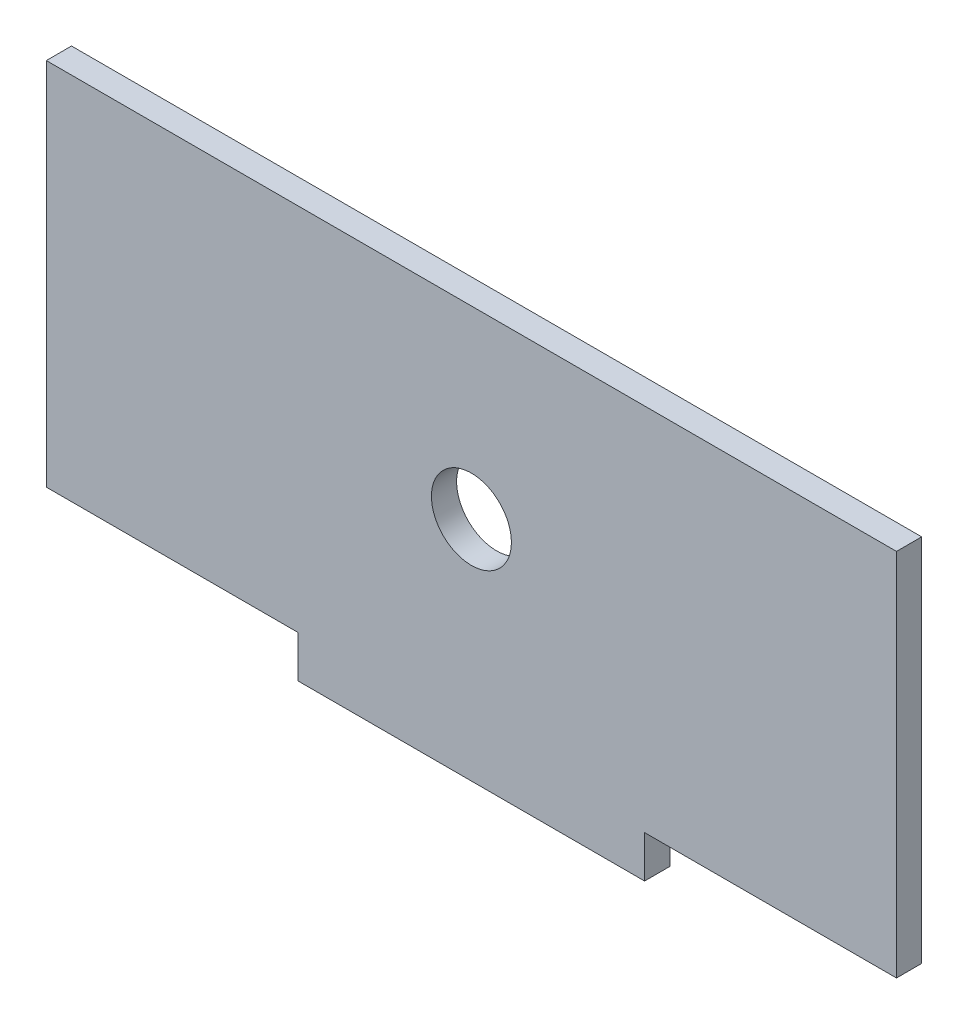
from build123d import *

# Parameters (mm, degrees)
BOSS_EXTRUDE1_DEPTH        = 3
F_3_8_0_3750_DOWEL_HOLE1_D = 9.525


with BuildPart() as part:
    # Sketch1 → Boss-Extrude1 (new body)
    with BuildSketch(Plane.XY):
        Polygon((-50.625, 0), (-50.625, -44), (-20.625, -44), (-20.625, -49), (20.625, -49), (20.625, -44), (50.625, -44), (50.625, 0), align=None)
    extrude(amount=BOSS_EXTRUDE1_DEPTH)

    # 3/8 (0.3750) Dowel Hole1 (through all)
    with Locations(Plane.XY.offset(3)):
        with Locations((0, -22)):
            Hole(F_3_8_0_3750_DOWEL_HOLE1_D / 2)


solid = part.part
